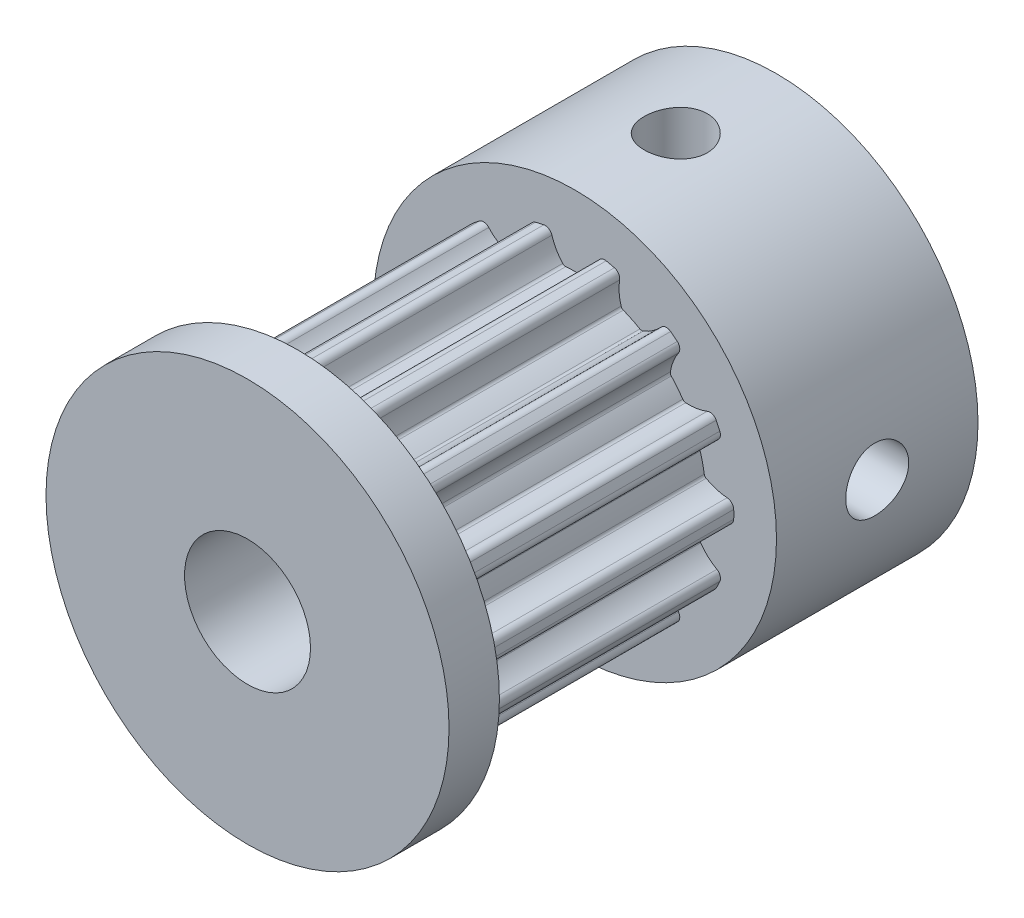
from build123d import *

# Parameters (mm, degrees)
SKETCH_1_R               = 6.305
EXTRUDE_1_DEPTH          = 5.5
CUT_EXTRUDE_START        = -12
CUT_EXTRUDE_1_DEPTH      = 13
PATTERN_CIRCULAR_1_COUNT = 14
SKETCH_3_R               = 8
EXTRUDE_2_DEPTH          = 2
SKETCH_5_R               = 8
EXTRUDE_3_DEPTH          = 8
SKETCH_4_R               = 2.5
CUT_EXTRUDE_2_DEPTH      = 22
SKETCH_7_W               = 1.25
SKETCH_7_H               = 8
PATTERN_CIRCULAR_2_COUNT = 2
PATTERN_CIRCULAR_2_ANGLE = 90


with BuildPart() as part:
    # 草圖1 → 填料-伸長1 (new body, symmetric)
    with BuildSketch(Plane.XY):
        Circle(SKETCH_1_R)
    extrude(amount=EXTRUDE_1_DEPTH, both=True)

    # 草圖2 → 除料-伸長1 (cut)
    with BuildSketch(Plane.XY.offset(5.5).offset(CUT_EXTRUDE_START)):
        with BuildLine():
            Line((-39.653021357, -1.515962662), (-1.238867566, 6.182089627))
            ThreePointArc((-1.238867566, 6.182089627), (-1.039898347, 6.14770999), (-0.915789196, 5.988437808))
            ThreePointArc((-0.915789196, 5.988437808), (-0.743543104, 5.58574022), (-0.486778479, 5.23090788))
            ThreePointArc((-0.486778479, 5.23090788), (-0.431598805, 5.192557356), (-0.365212221, 5.182146759))
            ThreePointArc((-0.365212221, 5.182146759), (0, 5.195), (0.365212221, 5.182146759))
            ThreePointArc((0.365212221, 5.182146759), (0.431598805, 5.192557356), (0.486778479, 5.23090788))
            ThreePointArc((0.486778479, 5.23090788), (0.743543104, 5.58574022), (0.915789196, 5.988437808))
            ThreePointArc((0.915789196, 5.988437808), (1.039898347, 6.14770999), (1.238867566, 6.182089627))
            Line((1.238867566, 6.182089627), (39.653021357, -1.515962662))
            Line((39.653021357, -1.515962662), (39.653021357, 76.839821312))
            Line((39.653021357, 76.839821312), (-39.653021357, 76.839821312))
            Line((-39.653021357, 76.839821312), (-39.653021357, -1.515962662))
        make_face()
    cut_extrude_1 = extrude(amount=CUT_EXTRUDE_1_DEPTH, mode=Mode.SUBTRACT)

    # 環狀複製排列1: 除料-伸長1 ×14 about axis
    pattern_circular_1_axis = Axis((0, 0, 5.5), (0, 0, 1))
    for i in range(1, PATTERN_CIRCULAR_1_COUNT):
        add(cut_extrude_1.rotate(pattern_circular_1_axis, i * 360 / PATTERN_CIRCULAR_1_COUNT), mode=Mode.SUBTRACT)

    # 草圖3 → 填料-伸長2 (add)
    with BuildSketch(Plane.XY.offset(5.5)):
        Circle(SKETCH_3_R)
    extrude(amount=EXTRUDE_2_DEPTH)

    # 草圖5 → 填料-伸長3 (add)
    with BuildSketch(Plane(origin=(0, 0, -5.5), x_dir=(-1, 0, 0), z_dir=(0, 0, -1))):
        Circle(SKETCH_5_R)
    extrude(amount=EXTRUDE_3_DEPTH)

    # 草圖4 → 除料-伸長2 (cut, through all)
    with BuildSketch(Plane.XY.offset(7.5)):
        Circle(SKETCH_4_R)
    extrude(amount=-CUT_EXTRUDE_2_DEPTH, mode=Mode.SUBTRACT)

    # 草圖7 → M3x0.5 螺紋孔1 (revolve, cut)
    with BuildSketch(Plane(origin=(0, 0, -9.5), x_dir=(0, 0, -1), z_dir=(1, 0, 0))):
        with Locations((0.625, 4)):
            Rectangle(SKETCH_7_W, SKETCH_7_H)
    m3x0_5_1 = revolve(axis=Axis((0, -6.35, -9.5), (0, 1, 0)), mode=Mode.SUBTRACT)

    # 環狀複製排列2: M3x0.5 螺紋孔1 ×2 about axis
    pattern_circular_2_axis = Axis((0, 0, -13.5), (0, 0, -1))
    for i in range(1, PATTERN_CIRCULAR_2_COUNT):
        add(m3x0_5_1.rotate(pattern_circular_2_axis, i * PATTERN_CIRCULAR_2_ANGLE / (PATTERN_CIRCULAR_2_COUNT - 1)), mode=Mode.SUBTRACT)


solid = part.part
